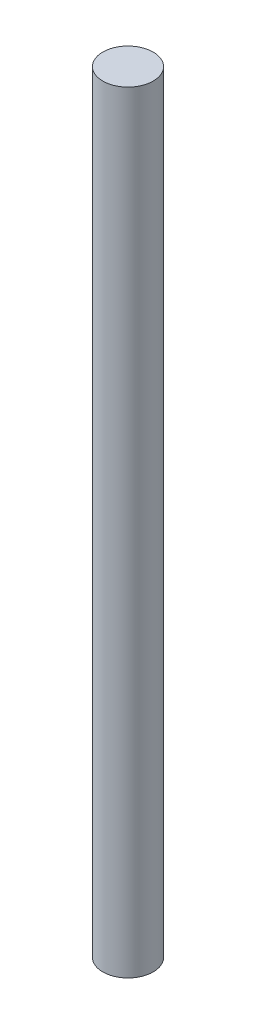
from build123d import *

# Parameters (mm, degrees)
PROFILE_SKETCH_R    = 4
BOSS_EXTRUDE1_DEPTH = 122.585779974


with BuildPart() as part:
    # Profile Sketch → Boss-Extrude1 (new body)
    with BuildSketch(Plane(origin=(0, 0, 0), x_dir=(1, 0, 0), z_dir=(0, 1, 0))):
        Circle(PROFILE_SKETCH_R)
    extrude(amount=BOSS_EXTRUDE1_DEPTH)


solid = part.part
